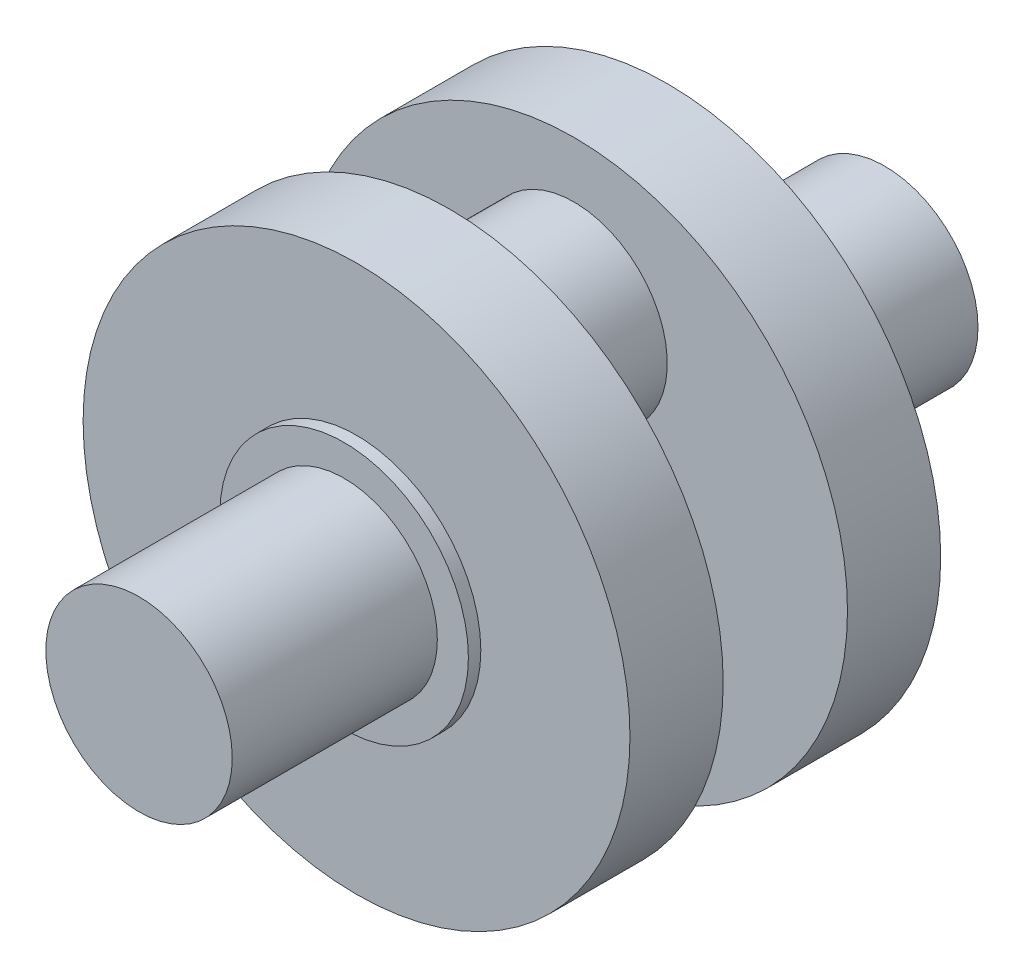
from build123d import *

# Parameters (mm, degrees)
SZKIC2_R                    = 15
DODANIE_WYCI_GNI_CIE1_DEPTH = 33
SZKIC3_R                    = 20
DODANIE_WYCI_GNI_CIE2_DEPTH = 2
SZKIC4_R                    = 44
DODANIE_WYCI_GNI_CIE3_DEPTH = 15
SZKIC5_R                    = 15
DODANIE_WYCI_GNI_CIE4_DEPTH = 10


with BuildPart() as part:
    # Szkic2 → Dodanie-wyciągnięcie1 (new body)
    with BuildSketch(Plane.XY):
        Circle(SZKIC2_R)
    extrude(amount=DODANIE_WYCI_GNI_CIE1_DEPTH)

    # Szkic3 → Dodanie-wyciągnięcie2 (add)
    with BuildSketch(Plane.XY):
        Circle(SZKIC3_R)
    extrude(amount=-DODANIE_WYCI_GNI_CIE2_DEPTH)

    # Szkic4 → Dodanie-wyciągnięcie3 (add)
    with BuildSketch(Plane(origin=(0, 0, -2), x_dir=(-1, 0, 0), z_dir=(0, 0, -1))):
        Circle(SZKIC4_R)
    extrude(amount=DODANIE_WYCI_GNI_CIE3_DEPTH)

    # Szkic5 → Dodanie-wyciągnięcie4 (add)
    with BuildSketch(Plane(origin=(0, 0, -17), x_dir=(-1, 0, 0), z_dir=(0, 0, -1))):
        with Locations((0, 20)):
            Circle(SZKIC5_R)
    extrude(amount=DODANIE_WYCI_GNI_CIE4_DEPTH)

    # Lustro1: part across plane


with BuildPart() as part_1:
    add(part.part)
    add(part.part.mirror(Plane(origin=(0, 20, -27), x_dir=(1, 0, 0), z_dir=(0, 0, -1))))


solid = part_1.part
